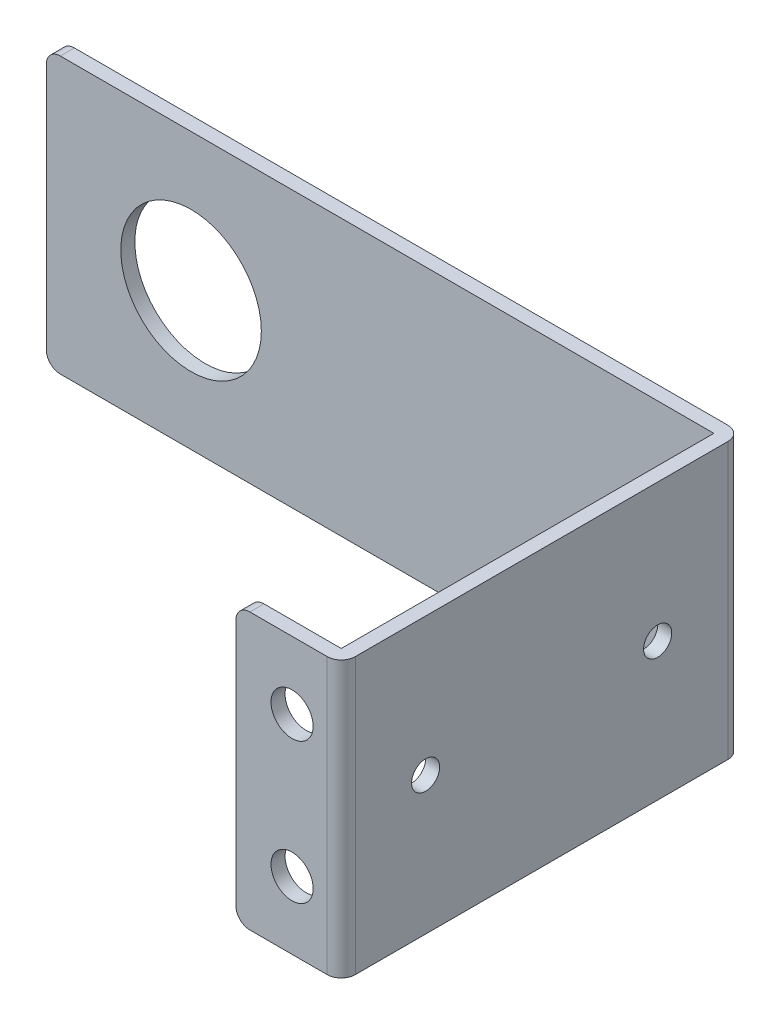
from build123d import *

# Parameters (mm, degrees)
SKETCH1_W           = 47.5
SKETCH1_H           = 19.6
SKETCH1_R           = 5
BOSS_EXTRUDE1_DEPTH = 1
BOSS_EXTRUDE2_START = -1
SKETCH2_W           = 1
SKETCH2_H           = 19.6
BOSS_EXTRUDE2_DEPTH = 28.512
SKETCH3_W           = 1
SKETCH3_H           = 19.6
BOSS_EXTRUDE3_DEPTH = 6.5
CUT_EXTRUDE1_REACH  = 30.512
SKETCH4_R           = 1.5
SKETCH6_R           = 1
CUT_EXTRUDE2_DEPTH  = 6.5
FILLET1_R           = 1


with BuildPart() as part:
    # Sketch1 → Boss-Extrude1 (new body)
    with BuildSketch(Plane.XY):
        Rectangle(SKETCH1_W, SKETCH1_H)
        with Locations((-13.45, 0)):
            Circle(SKETCH1_R, mode=Mode.SUBTRACT)
    extrude(amount=BOSS_EXTRUDE1_DEPTH)

    # Sketch2 → Boss-Extrude2 (add)
    with BuildSketch(Plane.XY.offset(1).offset(BOSS_EXTRUDE2_START)):
        with Locations((24.25, 0)):
            Rectangle(SKETCH2_W, SKETCH2_H)
    extrude(amount=BOSS_EXTRUDE2_DEPTH)

    # Sketch3 → Boss-Extrude3 (add)
    with BuildSketch(Plane.ZY.offset(-23.75)):
        with Locations((28.012, 0)):
            Rectangle(SKETCH3_W, SKETCH3_H)
    extrude(amount=BOSS_EXTRUDE3_DEPTH)

    # Sketch4 → Cut-Extrude1 (cut, up to next)
    with BuildSketch(Plane.XY.offset(28.512), mode=Mode.PRIVATE) as cut_extrude1_sk1:
        with Locations((21.25, 5)):
            Circle(SKETCH4_R)
    cut_extrude1_tool1 = extrude(cut_extrude1_sk1.sketch, amount=-CUT_EXTRUDE1_REACH, mode=Mode.PRIVATE) & part.part
    add(cut_extrude1_tool1.solids().sort_by_distance((21.25, 5, 28.512))[0], mode=Mode.SUBTRACT)
    # Sketch4 → Cut-Extrude1 (cut, up to next)
    with BuildSketch(Plane.XY.offset(28.512), mode=Mode.PRIVATE) as cut_extrude1_sk2:
        with Locations((21.25, -5)):
            Circle(SKETCH4_R)
    cut_extrude1_tool2 = extrude(cut_extrude1_sk2.sketch, amount=-CUT_EXTRUDE1_REACH, mode=Mode.PRIVATE) & part.part
    add(cut_extrude1_tool2.solids().sort_by_distance((21.25, -5, 28.512))[0], mode=Mode.SUBTRACT)

    # Sketch6 → Cut-Extrude2 (cut)
    with BuildSketch(Plane.ZY.offset(-23.75)):
        with Locations((6, 0)):
            Circle(SKETCH6_R)
        with Locations((22.512, 0)):
            Circle(SKETCH6_R)
    extrude(amount=-CUT_EXTRUDE2_DEPTH, mode=Mode.SUBTRACT)

    # Fillet1
    fillet1_edges = [part.edges().sort_by_distance(p)[0] for p in [
        (-23.75, 9.8, 0.5),
        (-23.75, -9.8, 0.5),
        (17.25, -9.8, 28.012),
        (17.25, 9.8, 28.012),
        (24.75, 0, 0),
        (24.75, 0, 28.512),
    ]]
    fillet(fillet1_edges, radius=FILLET1_R)


solid = part.part
